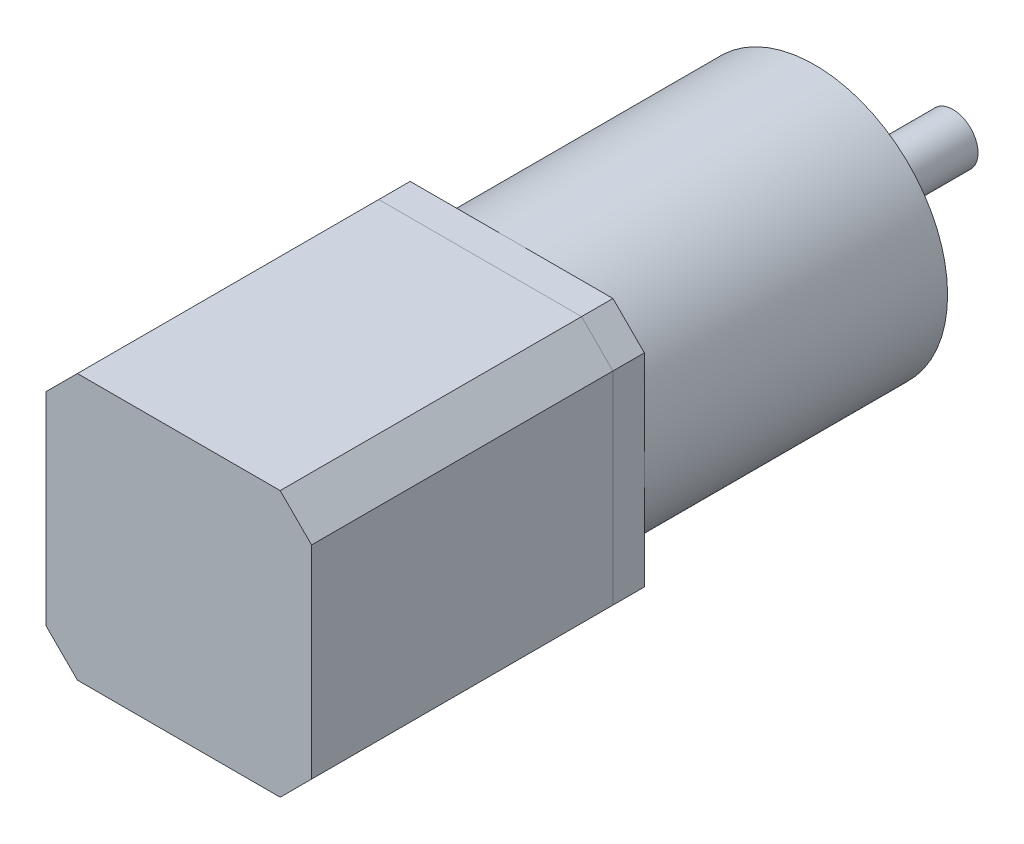
from build123d import *

# Parameters (mm, degrees)
SKETCH1_W           = 42.3
SKETCH1_H           = 42.3
BOSS_EXTRUDE1_DEPTH = 48
CHAMFER1_SIZE       = 5
SKETCH2_W           = 42.3
SKETCH2_H           = 42.3
BOSS_EXTRUDE2_DEPTH = 5
CHAMFER2_SIZE       = 5
SKETCH3_R           = 21.15
BOSS_EXTRUDE3_DEPTH = 48.3
SKETCH4_R           = 11
BOSS_EXTRUDE4_DEPTH = 2
SKETCH5_R           = 4
BOSS_EXTRUDE5_DEPTH = 20
SKETCH6_R           = 6.210975092
BOSS_EXTRUDE6_DEPTH = 0.5
SKETCH7_R           = 1.5
CUT_EXTRUDE2_DEPTH  = 10


with BuildPart() as part:
    # Sketch1 → Boss-Extrude1 (new body)
    with BuildSketch(Plane.XY):
        Rectangle(SKETCH1_W, SKETCH1_H)
    extrude(amount=BOSS_EXTRUDE1_DEPTH)

    # Chamfer1
    chamfer1_edges = [part.edges().sort_by_distance(p)[0] for p in [
        (21.15, -21.15, 24),
        (-21.15, -21.15, 24),
        (-21.15, 21.15, 24),
        (21.15, 21.15, 24),
    ]]
    chamfer(chamfer1_edges, length=CHAMFER1_SIZE)


with BuildPart() as body_2:
    # Sketch2 → Boss-Extrude2 (new body)
    with BuildSketch(Plane(origin=(0, 0, 0), x_dir=(-1, 0, 0), z_dir=(0, 0, -1))):
        Rectangle(SKETCH2_W, SKETCH2_H)
    extrude(amount=BOSS_EXTRUDE2_DEPTH)

    # Chamfer2
    chamfer2_edges = [body_2.edges().sort_by_distance(p)[0] for p in [
        (-21.15, -21.15, -2.5),
        (21.15, -21.15, -2.5),
        (21.15, 21.15, -2.5),
        (-21.15, 21.15, -2.5),
    ]]
    chamfer(chamfer2_edges, length=CHAMFER2_SIZE)


with BuildPart() as body_3:
    # Sketch3 → Boss-Extrude3 (new body)
    with BuildSketch(Plane(origin=(0, 0, -5), x_dir=(-1, 0, 0), z_dir=(0, 0, -1))):
        Circle(SKETCH3_R)
    extrude(amount=BOSS_EXTRUDE3_DEPTH)

    # Sketch7 → Cut-Extrude2 (cut)
    with BuildSketch(Plane(origin=(0, 0, -53.3), x_dir=(-1, 0, 0), z_dir=(0, 0, -1))):
        with Locations((-17.5, 0)):
            Circle(SKETCH7_R)
        with Locations((0, 17.5)):
            Circle(SKETCH7_R)
        with Locations((17.5, 0)):
            Circle(SKETCH7_R)
        with Locations((0, -17.5)):
            Circle(SKETCH7_R)
    extrude(amount=-CUT_EXTRUDE2_DEPTH, mode=Mode.SUBTRACT)


with BuildPart() as body_4:
    # Sketch4 → Boss-Extrude4 (new body)
    with BuildSketch(Plane(origin=(0, 0, -53.3), x_dir=(-1, 0, 0), z_dir=(0, 0, -1))):
        Circle(SKETCH4_R)
    extrude(amount=BOSS_EXTRUDE4_DEPTH)


with BuildPart() as body_5:
    # Sketch5 → Boss-Extrude5 (new body)
    with BuildSketch(Plane(origin=(0, 0, -55.3), x_dir=(-1, 0, 0), z_dir=(0, 0, -1))):
        Circle(SKETCH5_R)
    extrude(amount=BOSS_EXTRUDE5_DEPTH)


with BuildPart() as body_6:
    # Sketch6 → Boss-Extrude6 (new body)
    with BuildSketch(Plane(origin=(0, 0, -55.3), x_dir=(-1, 0, 0), z_dir=(0, 0, -1))):
        Circle(SKETCH6_R)
    extrude(amount=BOSS_EXTRUDE6_DEPTH)


solid = Compound([part.part, body_2.part, body_3.part, body_4.part, body_5.part, body_6.part])
